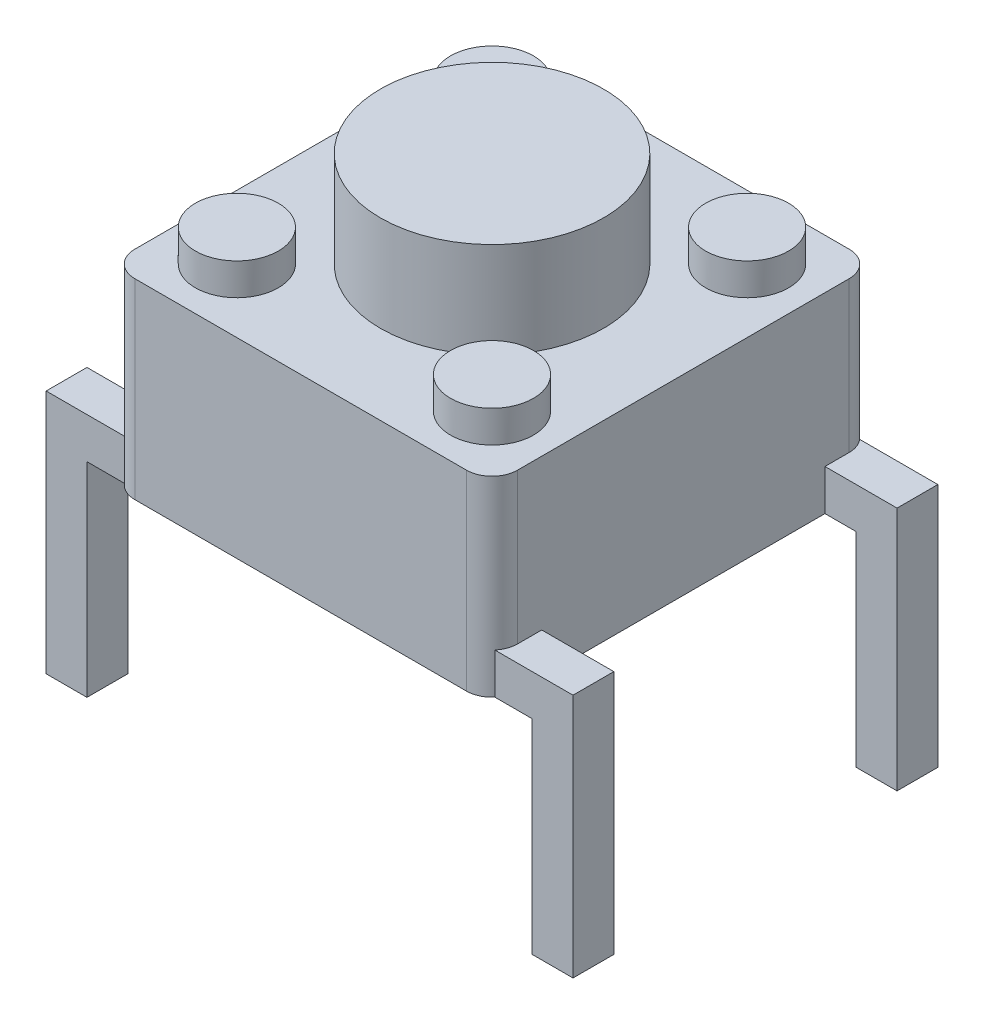
from build123d import *

# Parameters (mm, degrees)
SKETCH1_W             = 6
SKETCH1_H             = 6
BOSS_EXTRUDE1_DEPTH   = 3
SKETCH2_R             = 1.75
BOSS_EXTRUDE2_DEPTH   = 1.5
SKETCH3_R             = 0.65
BOSS_EXTRUDE3_DEPTH   = 0.5
SKETCH4_W             = 0.64
SKETCH4_H             = 0.64
BOSS_EXTRUDE4_DEPTH   = 3.2
BOSS_EXTRUDE4_2_DEPTH = 3.2
BOSS_EXTRUDE4_3_DEPTH = 3.2
BOSS_EXTRUDE4_4_DEPTH = 3.2
FILLET1_R             = 0.4
SKETCH6_W             = 0.64
SKETCH6_H             = 0.64
BOSS_EXTRUDE6_DEPTH   = 8.26


with BuildPart() as part:
    # Sketch1 → Boss-Extrude1 (new body)
    with BuildSketch(Plane(origin=(0, 0, 0), x_dir=(1, 0, 0), z_dir=(0, 1, 0))):
        Rectangle(SKETCH1_W, SKETCH1_H)
    extrude(amount=BOSS_EXTRUDE1_DEPTH)

    # Sketch2 → Boss-Extrude2 (add)
    with BuildSketch(Plane(origin=(0, 3, 0), x_dir=(1, 0, 0), z_dir=(0, 1, 0))):
        Circle(SKETCH2_R)
    extrude(amount=BOSS_EXTRUDE2_DEPTH)

    # Sketch3 → Boss-Extrude3 (add)
    with BuildSketch(Plane(origin=(0, 3, 0), x_dir=(1, 0, 0), z_dir=(0, 1, 0))):
        with Locations((-2, 2)):
            Circle(SKETCH3_R)
        with Locations((-2, -2)):
            Circle(SKETCH3_R)
        with Locations((2, -2)):
            Circle(SKETCH3_R)
        with Locations((2, 2)):
            Circle(SKETCH3_R)
    extrude(amount=BOSS_EXTRUDE3_DEPTH)

    # Fillet1
    fillet1_edges = [part.edges().sort_by_distance(p)[0] for p in [
        (3, 1.5, 3),
        (-3, 1.5, 3),
        (-3, 1.5, -3),
        (3, 1.5, -3),
    ]]
    fillet(fillet1_edges, radius=FILLET1_R)



with BuildPart() as body_2:
    # Sketch4 → Boss-Extrude4 (new body)
    with BuildSketch(Plane.XZ):
        with Locations((-3.81, 2.54)):
            Rectangle(SKETCH4_W, SKETCH4_H)
    extrude(amount=BOSS_EXTRUDE4_DEPTH)


with BuildPart() as body_3:
    # Sketch4 → Boss-Extrude4 2 (new body)
    with BuildSketch(Plane.XZ):
        with Locations((3.81, 2.54)):
            Rectangle(SKETCH4_W, SKETCH4_H)
    extrude(amount=BOSS_EXTRUDE4_2_DEPTH)


with BuildPart() as body_4:
    # Sketch4 → Boss-Extrude4 3 (new body)
    with BuildSketch(Plane.XZ):
        with Locations((3.81, -2.54)):
            Rectangle(SKETCH4_W, SKETCH4_H)
    extrude(amount=BOSS_EXTRUDE4_3_DEPTH)


with BuildPart() as body_5:
    # Sketch4 → Boss-Extrude4 4 (new body)
    with BuildSketch(Plane.XZ):
        with Locations((-3.81, -2.54)):
            Rectangle(SKETCH4_W, SKETCH4_H)
    extrude(amount=BOSS_EXTRUDE4_4_DEPTH)


with BuildPart() as part_1:
    add(part.part)

    add(body_2.part)  # Boss-Extrude6 merges body 2

    add(body_3.part)  # Boss-Extrude6 merges body 3

    add(body_4.part)  # Boss-Extrude6 merges body 4

    add(body_5.part)  # Boss-Extrude6 merges body 5
    # Sketch6 → Boss-Extrude6 (add)
    with BuildSketch(Plane.ZY.offset(4.13)):
        with Locations((-2.54, 0.32)):
            Rectangle(SKETCH6_W, SKETCH6_H)
        with Locations((2.54, 0.32)):
            Rectangle(SKETCH6_W, SKETCH6_H)
    extrude(amount=-BOSS_EXTRUDE6_DEPTH)


solid = part_1.part
